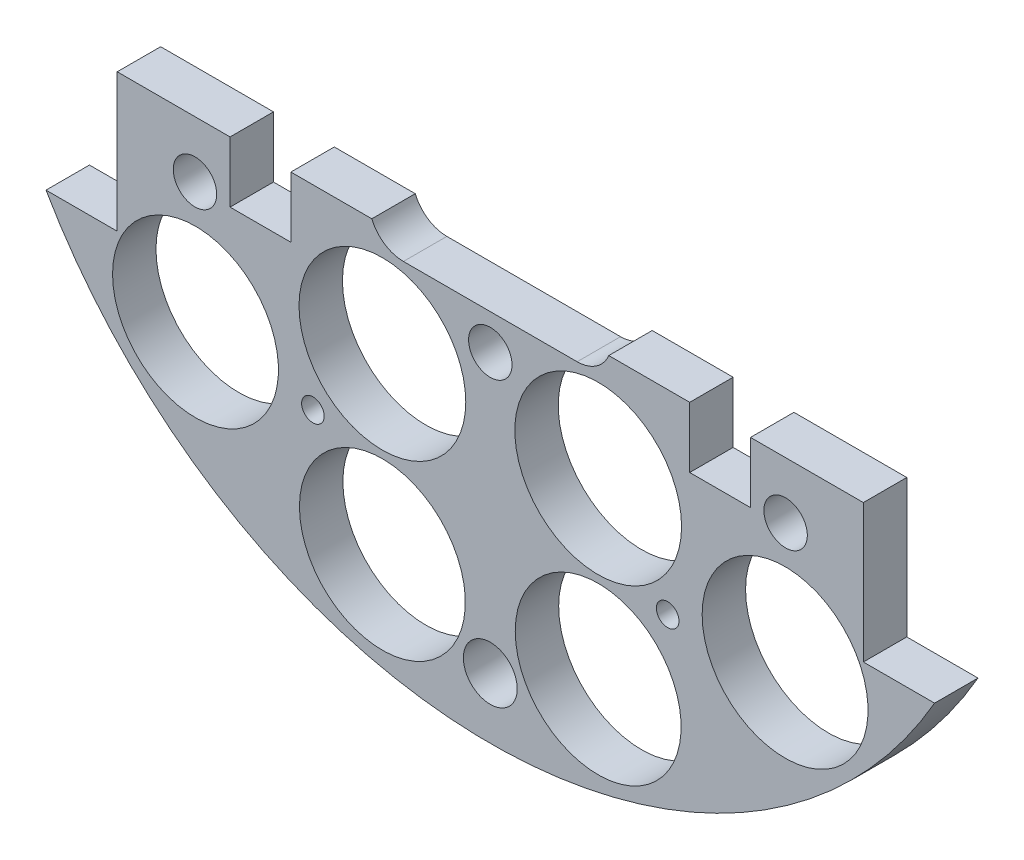
from build123d import *

# Parameters (mm, degrees)
SKETCH1_R           = 1.651
BOSS_EXTRUDE2_DEPTH = 6.35
SKETCH2_R           = 1.143
CUT_EXTRUDE1_DEPTH  = 7.35
SKETCH3_R           = 12.1285
CUT_EXTRUDE2_DEPTH  = 7.35
SKETCH4_W           = 28.562713242
SKETCH4_H           = 11.677503754
BOSS_EXTRUDE3_DEPTH = 6.35
SKETCH5_W           = 216.7214489
SKETCH5_H           = 130.569220634
CUT_EXTRUDE4_DEPTH  = 7.35
SKETCH11_R          = 3.937
CUT_EXTRUDE11_DEPTH = 7.35
SKETCH12_W          = 8.89
SKETCH12_H          = 8.89
CUT_EXTRUDE12_DEPTH = 7.35
SKETCH14_R          = 3.175
CUT_EXTRUDE14_DEPTH = 45.45
CUT_EXTRUDE15_DEPTH = 21.59
SKETCH16_R          = 12.192
CUT_EXTRUDE16_DEPTH = 21.59
SKETCH57_R          = 1.651
CUT_EXTRUDE57_DEPTH = 58.674


with BuildPart() as part:
    # Sketch1 → Boss-Extrude2 (new body)
    with BuildSketch(Plane.XY):
        with BuildLine():
            Line((-64.964441474, 37.338), (-54.550441474, 37.338))
            Line((-54.550441474, 37.338), (-54.550441474, -37.338))
            Line((-54.550441474, -37.338), (-64.964441474, -37.338))
            ThreePointArc((-64.964441474, -37.338), (0, -74.93), (64.964441474, -37.338))
            Line((64.964441474, -37.338), (54.550441474, -37.338))
            Line((54.550441474, -37.338), (54.550441474, 37.338))
            Line((54.550441474, 37.338), (64.964441474, 37.338))
            ThreePointArc((64.964441474, 37.338), (0, 74.93), (-64.964441474, 37.338))
        make_face()
        with Locations((-46.482, 11.049)):
            Circle(SKETCH1_R, mode=Mode.SUBTRACT)
        with Locations((-21.083270032, 10.795)):
            Circle(SKETCH1_R, mode=Mode.SUBTRACT)
        with Locations((-21.083270032, -10.795)):
            Circle(SKETCH1_R, mode=Mode.SUBTRACT)
        with Locations((-46.482, -11.049)):
            Circle(SKETCH1_R, mode=Mode.SUBTRACT)
        with Locations((46.482, -11.049)):
            Circle(SKETCH1_R, mode=Mode.SUBTRACT)
        with Locations((21.083270032, -10.795)):
            Circle(SKETCH1_R, mode=Mode.SUBTRACT)
        with Locations((21.083270032, 10.795)):
            Circle(SKETCH1_R, mode=Mode.SUBTRACT)
        with Locations((46.482, 11.049)):
            Circle(SKETCH1_R, mode=Mode.SUBTRACT)
    extrude(amount=BOSS_EXTRUDE2_DEPTH)

    # Sketch2 → Cut-Extrude1 (cut, through all)
    with BuildSketch(Plane.XY.offset(6.35)):
        with Locations((-6.731, 62.23)):
            Circle(SKETCH2_R)
        with Locations((6.731, 62.23)):
            Circle(SKETCH2_R)
    extrude(amount=-CUT_EXTRUDE1_DEPTH, mode=Mode.SUBTRACT)

    # Sketch3 → Cut-Extrude2 (cut, through all)
    with BuildSketch(Plane(origin=(0, 0, 0), x_dir=(-1, 0, 0), z_dir=(0, 0, -1))):
        with Locations((-15.777608989, -58.882838371)):
            Circle(SKETCH3_R)
        with Locations((15.777608989, -58.882838371)):
            Circle(SKETCH3_R)
        with Locations((-43.105229381, -43.105229381)):
            Circle(SKETCH3_R)
        with Locations((-43.105229381, 43.105229381)):
            Circle(SKETCH3_R)
        with Locations((43.105229381, 43.105229381)):
            Circle(SKETCH3_R)
        with Locations((43.105229381, -43.105229381)):
            Circle(SKETCH3_R)
    extrude(amount=-CUT_EXTRUDE2_DEPTH, mode=Mode.SUBTRACT)

    # Sketch4 → Boss-Extrude3 (add)
    with BuildSketch(Plane(origin=(0, 0, 0), x_dir=(-1, 0, 0), z_dir=(0, 0, -1))):
        with Locations((-1.488809975, 62.152540216)):
            Rectangle(SKETCH4_W, SKETCH4_H)
    extrude(amount=-BOSS_EXTRUDE3_DEPTH)

    # Sketch5 → Cut-Extrude4 (cut, through all)
    with BuildSketch(Plane(origin=(0, 0, 0), x_dir=(-1, 0, 0), z_dir=(0, 0, -1))):
        with Locations((23.316688373, 48.139610317)):
            Rectangle(SKETCH5_W, SKETCH5_H)
    extrude(amount=-CUT_EXTRUDE4_DEPTH, mode=Mode.SUBTRACT)

    # Sketch11 → Cut-Extrude11 (cut, through all)
    with BuildSketch(Plane(origin=(0, 0, 0), x_dir=(-1, 0, 0), z_dir=(0, 0, -1))):
        with Locations((0, -66.045)):
            Circle(SKETCH11_R)
    extrude(amount=-CUT_EXTRUDE11_DEPTH, mode=Mode.SUBTRACT)

    # Sketch12 → Cut-Extrude12 (cut, through all)
    with BuildSketch(Plane(origin=(0, 0, 0), x_dir=(-1, 0, 0), z_dir=(0, 0, -1))):
        with Locations((-33.605441474, -21.59)):
            Rectangle(SKETCH12_W, SKETCH12_H)
        with Locations((33.605441474, -21.59)):
            Rectangle(SKETCH12_W, SKETCH12_H)
    extrude(amount=-CUT_EXTRUDE12_DEPTH, mode=Mode.SUBTRACT)

    # Sketch14 → Cut-Extrude14 (cut, through all)
    with BuildSketch(Plane(origin=(30.092005081, 4.08352975, -38.1), x_dir=(-1, 0, 0), z_dir=(0, 0, -1))):
        with Locations((73.272005081, -29.48352975)):
            Circle(SKETCH14_R)
        with Locations((30.092005081, -29.48352975)):
            Circle(SKETCH14_R)
        with Locations((-13.087994919, -29.48352975)):
            Circle(SKETCH14_R)
    extrude(amount=-CUT_EXTRUDE14_DEPTH, mode=Mode.SUBTRACT)

    # Sketch15 → Cut-Extrude15 (cut)
    with BuildSketch(Plane(origin=(0, 0, 0), x_dir=(-1, 0, 0), z_dir=(0, 0, -1))):
        with BuildLine():
            Line((-12.7, -20.24), (-6.06, -20.24))
            Line((-6.06, -20.24), (12.7, -20.24))
            ThreePointArc((12.7, -20.24), (16.235533906, -11.704466094), (7.7, -15.24))
            Line((7.7, -15.24), (-1.06, -15.24))
            ThreePointArc((-1.06, -15.24), (-4.010609847, -10.6792983), (-9.38, -11.501337137))
            ThreePointArc((-9.38, -11.501337137), (-17.374040774, -13.464234575), (-12.7, -20.24))
        make_face()
    extrude(amount=-CUT_EXTRUDE15_DEPTH, mode=Mode.SUBTRACT)

    # Sketch16 → Cut-Extrude16 (cut)
    with BuildSketch(Plane(origin=(0, 0, 0), x_dir=(-1, 0, 0), z_dir=(0, 0, -1))):
        with Locations((15.777608989, -33.482838371)):
            Circle(SKETCH16_R)
        with Locations((-15.777608989, -33.482838371)):
            Circle(SKETCH16_R)
    extrude(amount=-CUT_EXTRUDE16_DEPTH, mode=Mode.SUBTRACT)

    # Sketch57 → Cut-Extrude57 (cut)
    with BuildSketch(Plane(origin=(0, 0, 0), x_dir=(-1, 0, 0), z_dir=(0, 0, -1))):
        with Locations((-25.937608989, -45.645229381)):
            Circle(SKETCH57_R)
        with Locations((25.937608989, -45.645229381)):
            Circle(SKETCH57_R)
    extrude(amount=-CUT_EXTRUDE57_DEPTH, mode=Mode.SUBTRACT)


solid = part.part
